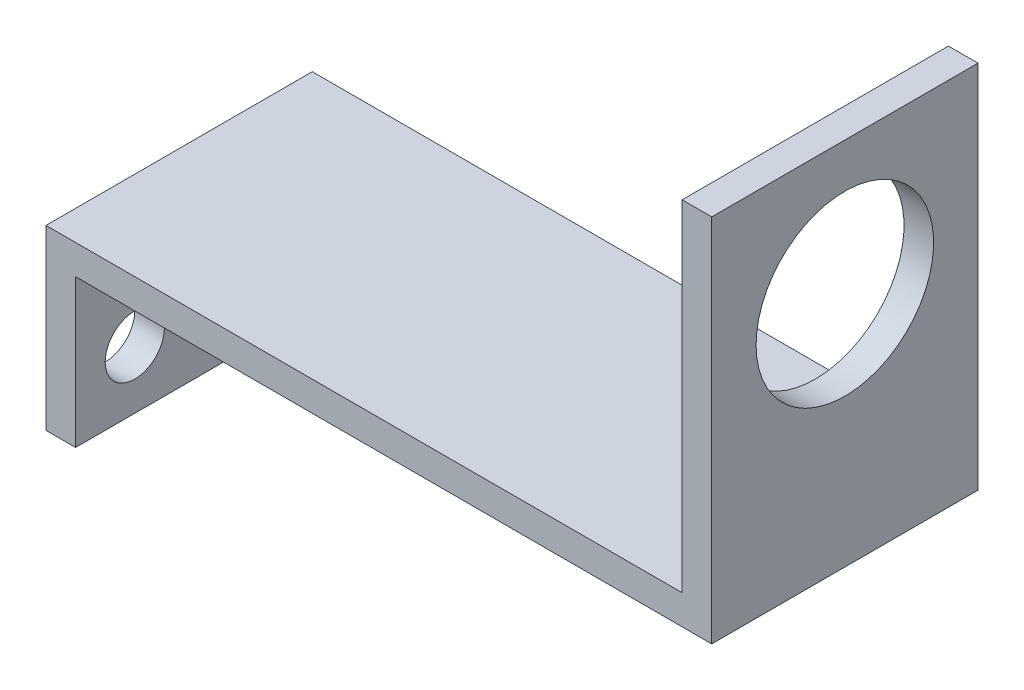
from build123d import *

# Parameters (mm, degrees)
BOSS_EXTRUDE1_DEPTH = 18
CUT_EXTRUDE1_REACH  = 47
SKETCH2_R           = 2
CUT_EXTRUDE2_REACH  = 4
SKETCH3_R           = 6


with BuildPart() as part:
    # Sketch1 → Boss-Extrude1 (new body)
    with BuildSketch(Plane.XY):
        Polygon((0, 0), (0, 12), (43, 12), (43, 35), (45, 35), (45, 10), (2, 10), (2, 0), align=None)
    extrude(amount=BOSS_EXTRUDE1_DEPTH)

    # Sketch2 → Cut-Extrude1 (cut, up to next)
    with BuildSketch(Plane.ZY, mode=Mode.PRIVATE) as cut_extrude1_sk1:
        with Locations((4, 4)):
            Circle(SKETCH2_R)
    cut_extrude1_tool1 = extrude(cut_extrude1_sk1.sketch, amount=-CUT_EXTRUDE1_REACH, mode=Mode.PRIVATE) & part.part
    add(cut_extrude1_tool1.solids().sort_by_distance((0, 4, 4))[0], mode=Mode.SUBTRACT)
    # Sketch2 → Cut-Extrude1 (cut, up to next)
    with BuildSketch(Plane.ZY, mode=Mode.PRIVATE) as cut_extrude1_sk2:
        with Locations((14, 4)):
            Circle(SKETCH2_R)
    cut_extrude1_tool2 = extrude(cut_extrude1_sk2.sketch, amount=-CUT_EXTRUDE1_REACH, mode=Mode.PRIVATE) & part.part
    add(cut_extrude1_tool2.solids().sort_by_distance((0, 4, 14))[0], mode=Mode.SUBTRACT)

    # Sketch3 → Cut-Extrude2 (cut, up to next)
    with BuildSketch(Plane.ZY.offset(-43), mode=Mode.PRIVATE) as cut_extrude2_sk1:
        with Locations((9, 26)):
            Circle(SKETCH3_R)
    cut_extrude2_tool1 = extrude(cut_extrude2_sk1.sketch, amount=-CUT_EXTRUDE2_REACH, mode=Mode.PRIVATE) & part.part
    add(cut_extrude2_tool1.solids().sort_by_distance((43, 26, 9))[0], mode=Mode.SUBTRACT)


solid = part.part
